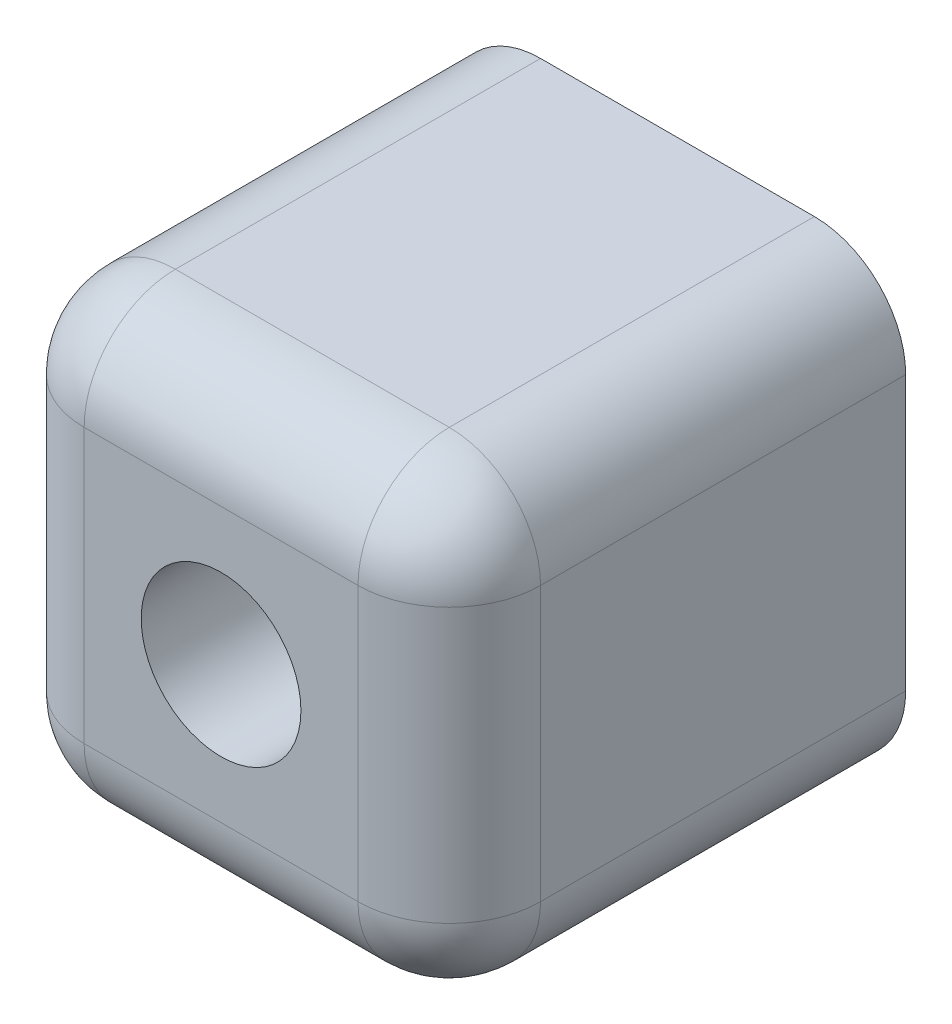
from build123d import *

# Parameters (mm, degrees)
SKETCH1_W           = 10
SKETCH1_H           = 10
BOSS_EXTRUDE1_DEPTH = 10
SKETCH2_R           = 1.75
CUT_EXTRUDE1_DEPTH  = 11
SKETCH3_R           = 2.304
CUT_EXTRUDE2_DEPTH  = 5
FILLET1_R           = 2
FILLET2_R           = 2


with BuildPart() as part:
    # Sketch1 → Boss-Extrude1 (new body)
    with BuildSketch(Plane.XY):
        with Locations((5, 5)):
            Rectangle(SKETCH1_W, SKETCH1_H)
    extrude(amount=BOSS_EXTRUDE1_DEPTH)

    # Sketch2 → Cut-Extrude1 (cut, through all)
    with BuildSketch(Plane.XY.offset(10)):
        with Locations((5, 5)):
            Circle(SKETCH2_R)
    extrude(amount=-CUT_EXTRUDE1_DEPTH, mode=Mode.SUBTRACT)

    # Sketch3 → Cut-Extrude2 (cut)
    with BuildSketch(Plane(origin=(0, 0, 0), x_dir=(-1, 0, 0), z_dir=(0, 0, -1))):
        with Locations((-5, 5)):
            Circle(SKETCH3_R)
    extrude(amount=-CUT_EXTRUDE2_DEPTH, mode=Mode.SUBTRACT)

    # Fillet1
    fillet1_edges = [part.edges().sort_by_distance(p)[0] for p in [
        (0, 10, 5),
        (10, 10, 5),
        (10, 0, 5),
        (0, 0, 5),
    ]]
    fillet(fillet1_edges, radius=FILLET1_R)

    # Fillet2
    fillet2_edges = [part.edges().sort_by_distance(p)[0] for p in [
        (5, 10, 10),
        (10, 5, 10),
        (0, 5, 10),
        (5, 0, 10),
        (9.414213562, 0.585786438, 10),
        (0.585786438, 0.585786438, 10),
        (0.585786438, 9.414213562, 10),
        (9.414213562, 9.414213562, 10),
    ]]
    fillet(fillet2_edges, radius=FILLET2_R)


solid = part.part
